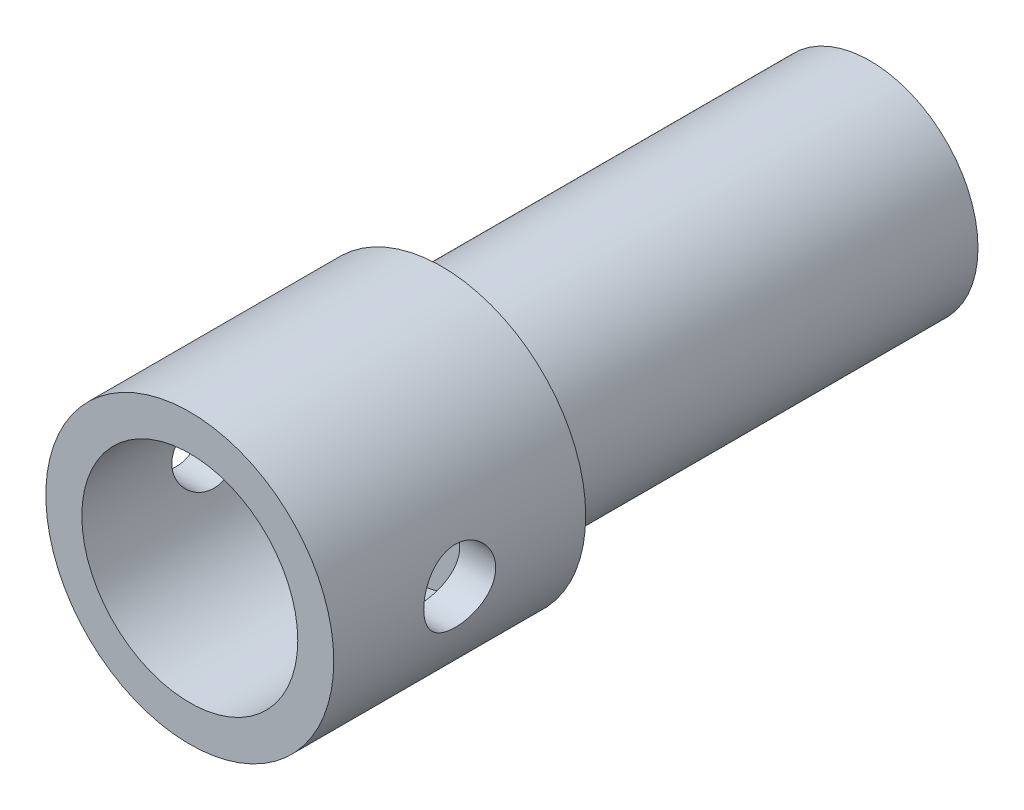
from build123d import *

# Parameters (mm, degrees)
SKETCH1_R                = 40
SKETCH1_R_2              = 30
BOSS_EXTRUDE1_DEPTH      = 70
SKETCH2_R                = 30
BOSS_EXTRUDE2_DEPTH      = 119
BOSS_EXTRUDE2_DEPTH_BACK = 10
CUT_EXTRUDE1_DEPTH       = 20
SKETCH5_R                = 10
CUT_EXTRUDE2_DEPTH       = 55


with BuildPart() as part:
    # Sketch1 → Boss-Extrude1 (new body)
    with BuildSketch(Plane.XY):
        Circle(SKETCH1_R)
        Circle(SKETCH1_R_2, mode=Mode.SUBTRACT)
    extrude(amount=-BOSS_EXTRUDE1_DEPTH)

    # Sketch2 → Boss-Extrude2 (add, two sides)
    with BuildSketch(Plane(origin=(0, 0, -70), x_dir=(-1, 0, 0), z_dir=(0, 0, -1))) as boss_extrude2_sk:
        Circle(SKETCH2_R)
    extrude(amount=BOSS_EXTRUDE2_DEPTH)
    extrude(boss_extrude2_sk.sketch, amount=-BOSS_EXTRUDE2_DEPTH_BACK)

    # Sketch4 → Cut-Extrude1 (cut)
    with BuildSketch(Plane(origin=(0, 0, -189), x_dir=(-1, 0, 0), z_dir=(0, 0, -1))):
        Polygon((8.5, -14.722431864), (17, 0), (8.5, 14.722431864), (-8.5, 14.722431864), (-17, 0), (-8.5, -14.722431864), align=None)
    extrude(amount=-CUT_EXTRUDE1_DEPTH, mode=Mode.SUBTRACT)

    # Sketch5 → Cut-Extrude2 (cut, symmetric)
    with BuildSketch(Plane(origin=(0, 0, 0), x_dir=(0, 0, -1), z_dir=(1, 0, 0))):
        with Locations((35, 0)):
            Circle(SKETCH5_R)
    extrude(amount=CUT_EXTRUDE2_DEPTH, both=True, mode=Mode.SUBTRACT)


solid = part.part
